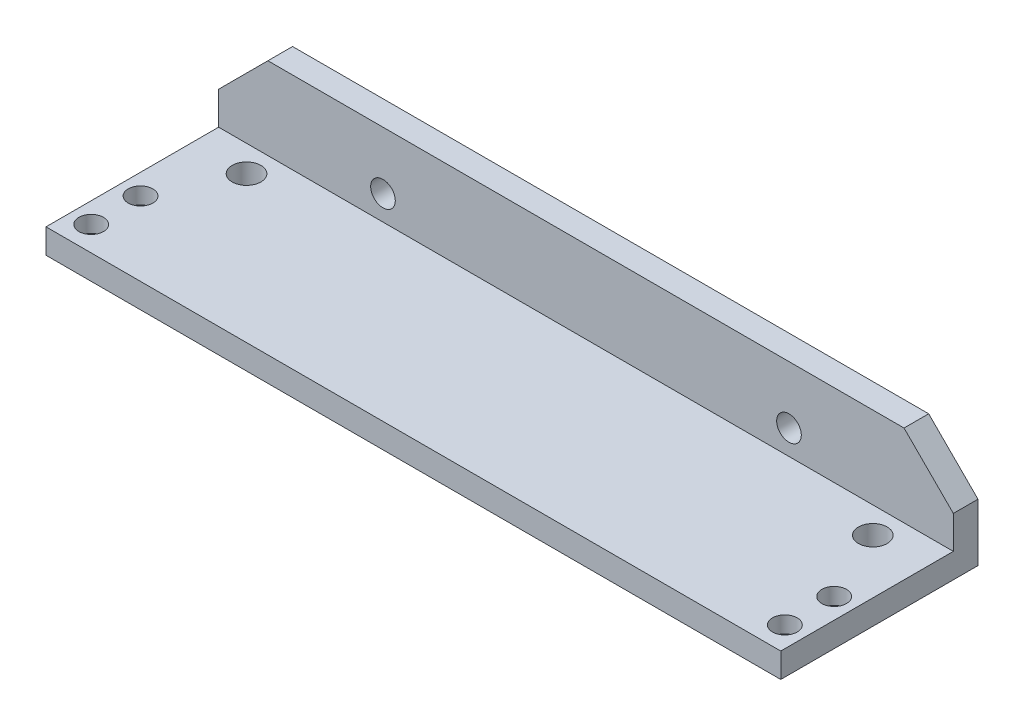
from build123d import *

# Parameters (mm, degrees)
SKETCH1_R           = 1.5
BOSS_EXTRUDE1_DEPTH = 3
SKETCH1_3_W         = 89.4
SKETCH1_3_H         = 3
BOSS_EXTRUDE2_DEPTH = 24
CUT_EXTRUDE1_REACH  = 5
SKETCH3_R           = 1.5
SKETCH3_R_2         = 1.75
CUT_EXTRUDE2_START  = -3
SKETCH3_5_R         = 2.25
SKETCH3_5_R_2       = 1.5
CUT_EXTRUDE2_DEPTH  = 1


with BuildPart() as part:
    # Sketch1 → Boss-Extrude1 (new body)
    with BuildSketch(Plane.XY):
        Polygon((-32.2510699, 8.892599614), (-38.2510699, 2.892599614), (-38.2510699, -1.107400386), (51.1489301, -1.107400386), (51.1489301, 2.892599614), (45.1489301, 8.892599614), align=None)
        with Locations((-18.2510699, 1.892599614)):
            Circle(SKETCH1_R, mode=Mode.SUBTRACT)
        with Locations((31.1489301, 1.892599614)):
            Circle(SKETCH1_R, mode=Mode.SUBTRACT)
    extrude(amount=BOSS_EXTRUDE1_DEPTH)

    # Sketch1_3 → Boss-Extrude2 (add)
    with BuildSketch(Plane.XY):
        with Locations((6.4489301, -2.607400386)):
            Rectangle(SKETCH1_3_W, SKETCH1_3_H)
    extrude(amount=BOSS_EXTRUDE2_DEPTH)

    # Sketch3 → Cut-Extrude1 (cut, up to next)
    with BuildSketch(Plane(origin=(0, -1.107400386, 0), x_dir=(1, 0, 0), z_dir=(0, 1, 0)), mode=Mode.PRIVATE) as cut_extrude1_sk1:
        with Locations((48.6489301, -15)):
            Circle(SKETCH3_R)
    cut_extrude1_tool1 = extrude(cut_extrude1_sk1.sketch, amount=-CUT_EXTRUDE1_REACH, mode=Mode.PRIVATE) & part.part
    add(cut_extrude1_tool1.solids().sort_by_distance((48.64893, -1.1074, 15))[0], mode=Mode.SUBTRACT)
    # Sketch3 → Cut-Extrude1 (cut, up to next)
    with BuildSketch(Plane(origin=(0, -1.107400386, 0), x_dir=(1, 0, 0), z_dir=(0, 1, 0)), mode=Mode.PRIVATE) as cut_extrude1_sk2:
        with Locations((48.6489301, -21)):
            Circle(SKETCH3_R)
    cut_extrude1_tool2 = extrude(cut_extrude1_sk2.sketch, amount=-CUT_EXTRUDE1_REACH, mode=Mode.PRIVATE) & part.part
    add(cut_extrude1_tool2.solids().sort_by_distance((48.64893, -1.1074, 21))[0], mode=Mode.SUBTRACT)
    # Sketch3 → Cut-Extrude1 (cut, up to next)
    with BuildSketch(Plane(origin=(0, -1.107400386, 0), x_dir=(1, 0, 0), z_dir=(0, 1, 0)), mode=Mode.PRIVATE) as cut_extrude1_sk3:
        with Locations((-35.7510699, -15)):
            Circle(SKETCH3_R)
    cut_extrude1_tool3 = extrude(cut_extrude1_sk3.sketch, amount=-CUT_EXTRUDE1_REACH, mode=Mode.PRIVATE) & part.part
    add(cut_extrude1_tool3.solids().sort_by_distance((-35.75107, -1.1074, 15))[0], mode=Mode.SUBTRACT)
    # Sketch3 → Cut-Extrude1 (cut, up to next)
    with BuildSketch(Plane(origin=(0, -1.107400386, 0), x_dir=(1, 0, 0), z_dir=(0, 1, 0)), mode=Mode.PRIVATE) as cut_extrude1_sk4:
        with Locations((-35.7510699, -21)):
            Circle(SKETCH3_R)
    cut_extrude1_tool4 = extrude(cut_extrude1_sk4.sketch, amount=-CUT_EXTRUDE1_REACH, mode=Mode.PRIVATE) & part.part
    add(cut_extrude1_tool4.solids().sort_by_distance((-35.75107, -1.1074, 21))[0], mode=Mode.SUBTRACT)
    # Sketch3 → Cut-Extrude1 (cut, up to next)
    with BuildSketch(Plane(origin=(0, -1.107400386, 0), x_dir=(1, 0, 0), z_dir=(0, 1, 0)), mode=Mode.PRIVATE) as cut_extrude1_sk5:
        with Locations((44.5489301, -6.2)):
            Circle(SKETCH3_R_2)
    cut_extrude1_tool5 = extrude(cut_extrude1_sk5.sketch, amount=-CUT_EXTRUDE1_REACH, mode=Mode.PRIVATE) & part.part
    add(cut_extrude1_tool5.solids().sort_by_distance((44.54893, -1.1074, 6.2))[0], mode=Mode.SUBTRACT)
    # Sketch3 → Cut-Extrude1 (cut, up to next)
    with BuildSketch(Plane(origin=(0, -1.107400386, 0), x_dir=(1, 0, 0), z_dir=(0, 1, 0)), mode=Mode.PRIVATE) as cut_extrude1_sk6:
        with Locations((-31.6510699, -6.2)):
            Circle(SKETCH3_R_2)
    cut_extrude1_tool6 = extrude(cut_extrude1_sk6.sketch, amount=-CUT_EXTRUDE1_REACH, mode=Mode.PRIVATE) & part.part
    add(cut_extrude1_tool6.solids().sort_by_distance((-31.65107, -1.1074, 6.2))[0], mode=Mode.SUBTRACT)

    # Sketch3_5 → Cut-Extrude2 (cut)
    with BuildSketch(Plane(origin=(0, -1.107400386, 0), x_dir=(1, 0, 0), z_dir=(0, 1, 0)).offset(CUT_EXTRUDE2_START)):
        with Locations((-35.7510699, -15)):
            Circle(SKETCH3_5_R)
        with Locations((-35.7510699, -15)):
            Circle(SKETCH3_5_R_2, mode=Mode.SUBTRACT)
        with Locations((-35.7510699, -21)):
            Circle(SKETCH3_5_R)
        with Locations((-35.7510699, -21)):
            Circle(SKETCH3_5_R_2, mode=Mode.SUBTRACT)
        with Locations((48.6489301, -15)):
            Circle(SKETCH3_5_R)
        with Locations((48.6489301, -21)):
            Circle(SKETCH3_5_R)
    extrude(amount=CUT_EXTRUDE2_DEPTH, mode=Mode.SUBTRACT)


solid = part.part
